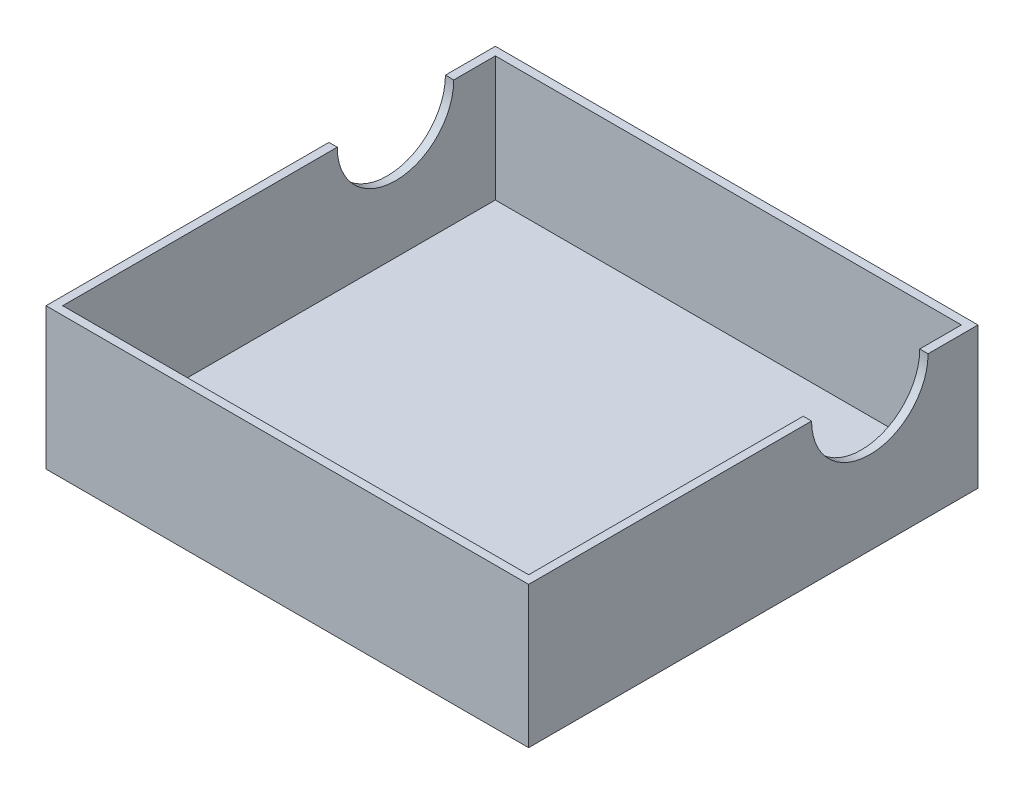
from build123d import *

# Parameters (mm, degrees)
ESQUISSE1_W             = 29
ESQUISSE1_H             = 27
BOSS_EXTRU_1_DEPTH      = 1
BOSS_EXTRU_2_DEPTH      = 7.5
ESQUISSE1_4_W           = 0.5
ESQUISSE1_4_H           = 7
BOSS_EXTRU_3_DEPTH      = 7.5
ESQUISSE7_R             = 3.5
ENL_V_MAT_EXTRU_1_DEPTH = 0.5
ENL_V_START             = -0.5
ESQUISSE6_R             = 3.5
ENL_V_MAT_EXTRU_2_DEPTH = 0.5


with BuildPart() as part:
    # Esquisse1 → Boss.-Extru.1 (new body)
    with BuildSketch(Plane(origin=(0, 0, 0), x_dir=(1, 0, 0), z_dir=(0, 1, 0))):
        with Locations((-8.325581395, -0.620930233)):
            Rectangle(ESQUISSE1_W, ESQUISSE1_H)
    extrude(amount=-BOSS_EXTRU_1_DEPTH)

    # Esquisse1_3 → Boss.-Extru.2 (add)
    with BuildSketch(Plane(origin=(0, 0, 0), x_dir=(1, 0, 0), z_dir=(0, 1, 0))):
        Polygon((-22.325581395, 8.379069767), (-22.325581395, 12.379069767), (5.674418605, 12.379069767), (5.674418605, 6.379069767), (6.174418605, 6.379069767), (6.174418605, 12.879069767), (-22.825581395, 12.879069767), (-22.825581395, 8.379069767), align=None)
        Polygon((-22.325581395, -13.620930233), (-22.325581395, 1.379069767), (-22.825581395, 1.379069767), (-22.825581395, -14.120930233), (6.174418605, -14.120930233), (6.174418605, -0.620930233), (5.674418605, -0.620930233), (5.674418605, -13.620930233), align=None)
    extrude(amount=BOSS_EXTRU_2_DEPTH)

    # Esquisse1_4 → Boss.-Extru.3 (add)
    with BuildSketch(Plane(origin=(0, 0, 0), x_dir=(1, 0, 0), z_dir=(0, 1, 0))):
        with Locations((-22.575581395, 4.879069767)):
            Rectangle(ESQUISSE1_4_W, ESQUISSE1_4_H)
        with Locations((5.924418605, 2.879069767)):
            Rectangle(ESQUISSE1_4_W, ESQUISSE1_4_H)
    extrude(amount=BOSS_EXTRU_3_DEPTH)

    # Esquisse7 → Enlèv. mat.-Extru.1 (cut)
    with BuildSketch(Plane(origin=(6.174418605, 0, 0), x_dir=(0, 0, -1), z_dir=(1, 0, 0))):
        with Locations((6.379069767, 7.5)):
            Circle(ESQUISSE7_R)
    extrude(amount=-ENL_V_MAT_EXTRU_1_DEPTH, mode=Mode.SUBTRACT)

    # Esquisse6 → Enlèv. mat.-Extru.2 (cut)
    with BuildSketch(Plane.ZY.offset(22.825581395).offset(ENL_V_START)):
        with Locations((-6.379069767, 7.5)):
            Circle(ESQUISSE6_R)
    extrude(amount=ENL_V_MAT_EXTRU_2_DEPTH, mode=Mode.SUBTRACT)


solid = part.part
